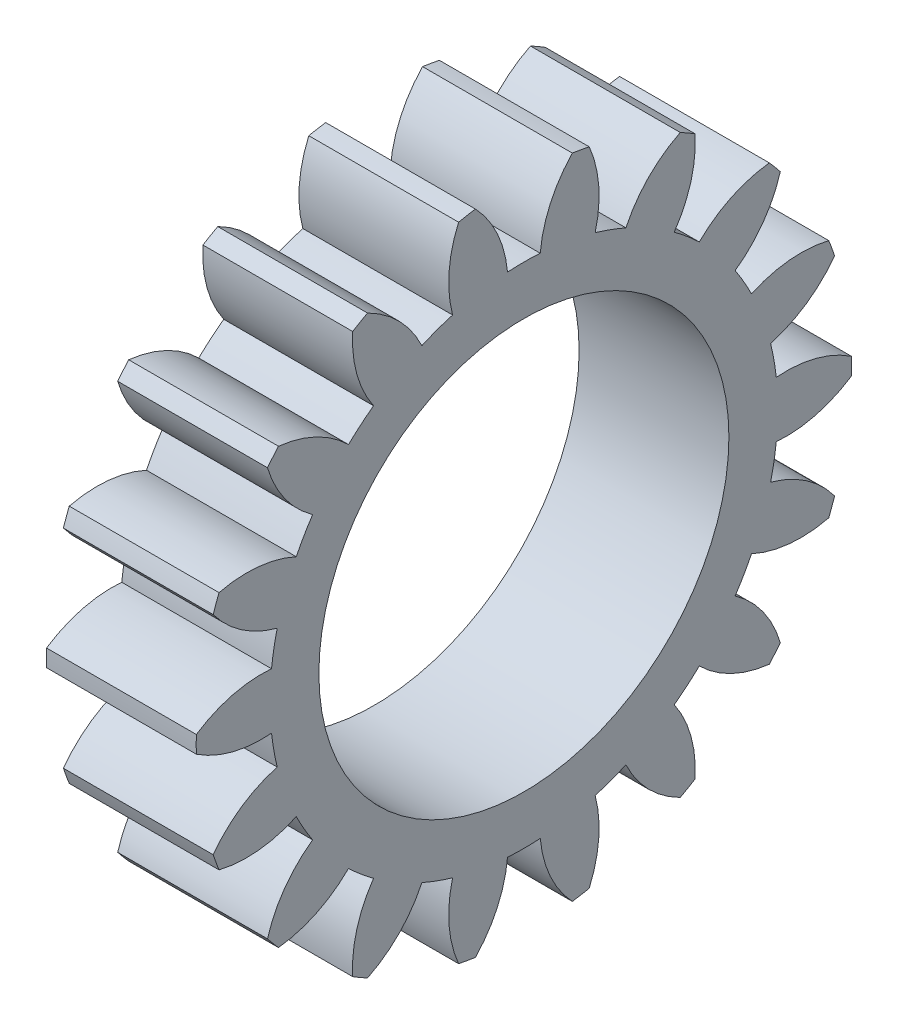
from build123d import *

# Parameters (mm, degrees)
BASPROSKE_W             = 8
BASPROSKE_H             = 17.5
TOOTHCUT_DEPTH          = 27.009613607
TEETHCUTS_COUNT         = 18
TEETHCUTS_ANGLE         = 340
BORSKE_R                = 4
BORE_DEPTH              = 50.0000508
ESQUISSE1_R             = 10.95
ENL_V_MAT_EXTRU_1_DEPTH = 10


with BuildPart() as part:
    # BasProSke → Base-Revolve (revolve)
    with BuildSketch(Plane(origin=(0, 0, 0), x_dir=(1, 0, 0), z_dir=(0, 1, 0)), mode=Mode.PRIVATE) as base_revolve_sk:
        with Locations((4, 8.75)):
            Rectangle(BASPROSKE_W, BASPROSKE_H)
    revolve(base_revolve_sk.sketch.rotate(Axis((-10, 0, 0), (1, 0, 0)), 180), axis=Axis((-10, 0, 0), (1, 0, 0)))

    # TooCutSke → ToothCut (cut, through all)
    with BuildSketch(Plane(origin=(0, 0, 0), x_dir=(0, 0, -1), z_dir=(1, 0, 0))):
        with BuildLine():
            ThreePointArc((0.873326889, 13.533350745), (0, 13.5615), (-0.873326889, 13.533350745))
            ThreePointArc((-0.873326889, 13.533350745), (-1.417662776, 15.579682129), (-2.609262071, 17.330072031))
            ThreePointArc((-2.609262071, 17.330072031), (0, 17.5254), (2.609262071, 17.330072031))
            ThreePointArc((2.609262071, 17.330072031), (1.417662776, 15.579682129), (0.873326889, 13.533350745))
        make_face()
    toothcut = extrude(amount=TOOTHCUT_DEPTH, mode=Mode.SUBTRACT)

    # TeethCuts: ToothCut ×18 about axis
    teethcuts_axis = Axis((-10, 0, 0), (1, 0, 0))
    for i in range(1, TEETHCUTS_COUNT):
        add(toothcut.rotate(teethcuts_axis, i * TEETHCUTS_ANGLE / (TEETHCUTS_COUNT - 1)), mode=Mode.SUBTRACT)

    # BorSke → Bore (cut, symmetric)
    with BuildSketch(Plane(origin=(0, 0, 0), x_dir=(0, 0, -1), z_dir=(1, 0, 0))):
        with Locations(Location((0, 0, 0), (0, 0, 180))):
            Circle(BORSKE_R)
    extrude(amount=BORE_DEPTH, both=True, mode=Mode.SUBTRACT)

    # Esquisse1 → Enlèv. mat.-Extru.1 (cut)
    with BuildSketch(Plane(origin=(8, 0, 0), x_dir=(0, 0, -1), z_dir=(1, 0, 0))):
        Circle(ESQUISSE1_R)
    extrude(amount=-ENL_V_MAT_EXTRU_1_DEPTH, mode=Mode.SUBTRACT)


solid = part.part
